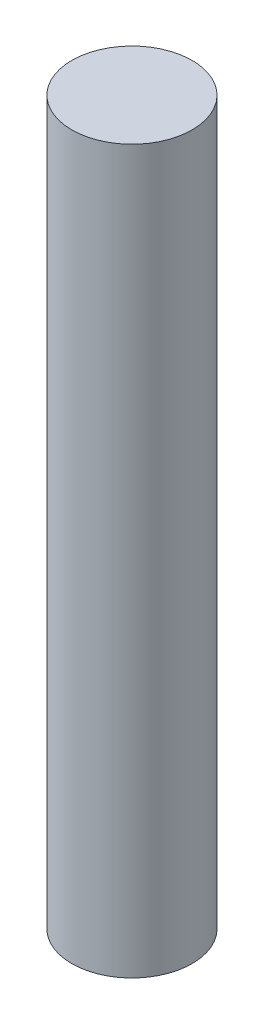
from build123d import *

# Parameters (mm, degrees)
SKETCH2_R           = 15.875
BOSS_EXTRUDE1_DEPTH = 190.5


with BuildPart() as part:
    # Sketch2 → Boss-Extrude1 (new body)
    with BuildSketch(Plane(origin=(0, 0, 0), x_dir=(1, 0, 0), z_dir=(0, 1, 0))):
        Circle(SKETCH2_R)
    extrude(amount=BOSS_EXTRUDE1_DEPTH)


solid = part.part
